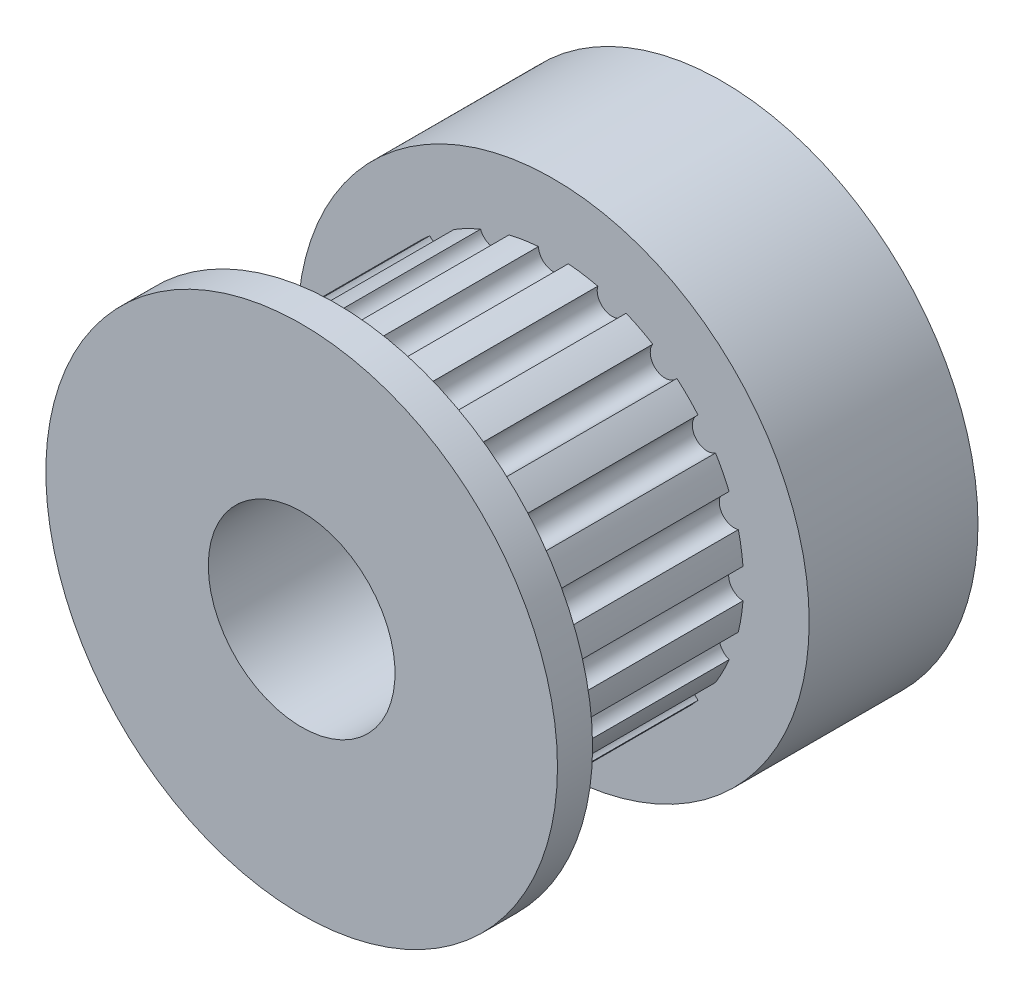
from build123d import *

# Parameters (mm, degrees)
SKETCH1_R           = 8.6995
BOSS_EXTRUDE1_DEPTH = 5.7404
SKETCH2_R           = 6.468056998
BOSS_EXTRUDE2_DEPTH = 7.366
SKETCH3_R           = 0.508
CUT_EXTRUDE1_DEPTH  = 7.366
CIRPATTERN1_COUNT   = 20
SKETCH4_R           = 8.6995
BOSS_EXTRUDE3_DEPTH = 1.1938
SKETCH5_R           = 3.175
CUT_EXTRUDE2_DEPTH  = 15.3002


with BuildPart() as part:
    # Sketch1 → Boss-Extrude1 (new body)
    with BuildSketch(Plane.XY):
        Circle(SKETCH1_R)
    extrude(amount=BOSS_EXTRUDE1_DEPTH)

    # Sketch2 → Boss-Extrude2 (add)
    with BuildSketch(Plane.XY.offset(5.7404)):
        Circle(SKETCH2_R)
    extrude(amount=BOSS_EXTRUDE2_DEPTH)

    # Sketch3 → Cut-Extrude1 (cut)
    with BuildSketch(Plane.XY.offset(13.1064)):
        with Locations((0, 6.468056998)):
            Circle(SKETCH3_R)
    cut_extrude1 = extrude(amount=-CUT_EXTRUDE1_DEPTH, mode=Mode.SUBTRACT)

    # CirPattern1: Cut-Extrude1 ×20 about axis
    cirpattern1_axis = Axis((0, 0, 0), (0, 0, 1))
    for i in range(1, CIRPATTERN1_COUNT):
        add(cut_extrude1.rotate(cirpattern1_axis, i * 360 / CIRPATTERN1_COUNT), mode=Mode.SUBTRACT)

    # Sketch4 → Boss-Extrude3 (add)
    with BuildSketch(Plane.XY.offset(13.1064)):
        Circle(SKETCH4_R)
    extrude(amount=BOSS_EXTRUDE3_DEPTH)

    # Sketch5 → Cut-Extrude2 (cut, through all)
    with BuildSketch(Plane(origin=(0, 0, 0), x_dir=(-1, 0, 0), z_dir=(0, 0, -1))):
        Circle(SKETCH5_R)
    extrude(amount=-CUT_EXTRUDE2_DEPTH, mode=Mode.SUBTRACT)


solid = part.part
